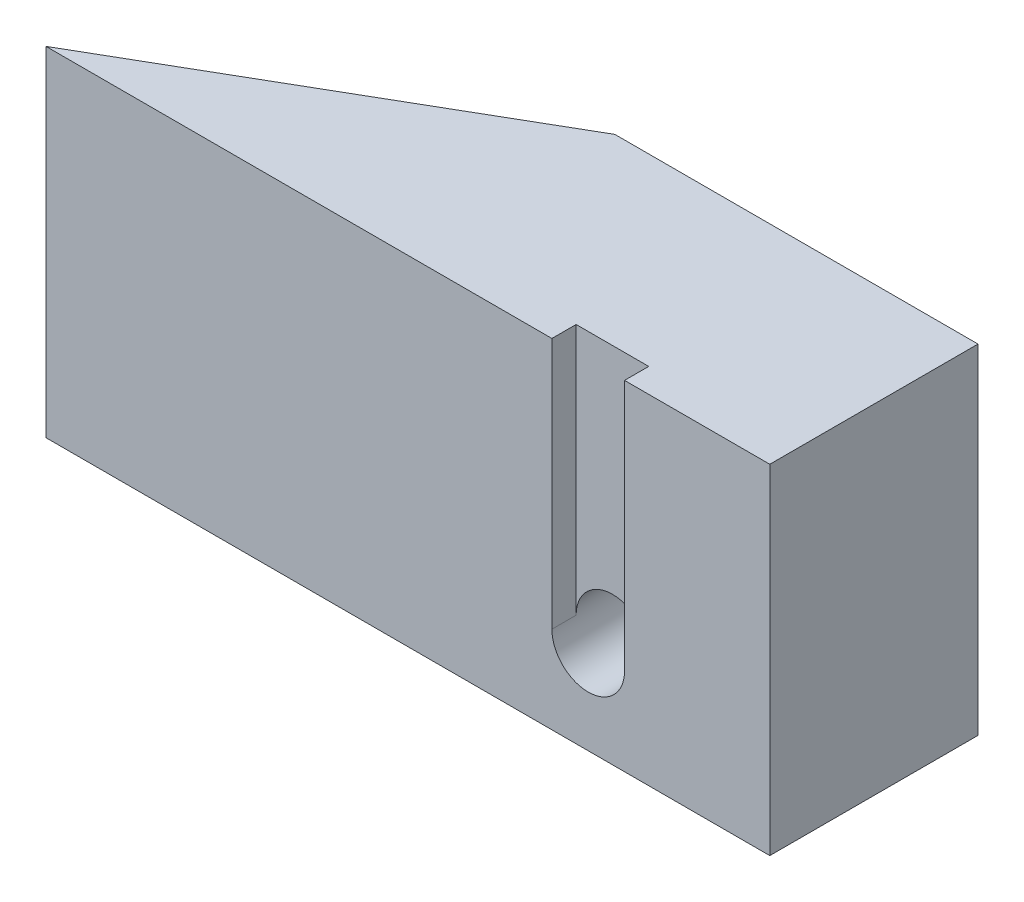
from build123d import *

# Parameters (mm, degrees)
BOSS_EXTRUDE1_DEPTH     = 70
SKETCH3_R               = 3
CUT_EXTRUDE1_DEPTH      = 44
SKETCH7_R               = 7.5
CUT_EXTRUDE3_DEPTH      = 1
CUT_EXTRUDE3_DEPTH_BACK = 30
SKETCH5_W               = 15
SKETCH5_H               = 52
CUT_EXTRUDE2_DEPTH      = 5


with BuildPart() as part:
    # Sketch1 → Boss-Extrude1 (new body)
    with BuildSketch(Plane(origin=(0, 0, 0), x_dir=(1, 0, 0), z_dir=(0, 1, 0))):
        Polygon((-111.978184725, 0), (37.5, 0), (37.5, 43), (-37.5, 43), align=None)
    extrude(amount=BOSS_EXTRUDE1_DEPTH)

    # Sketch3 → Cut-Extrude1 (cut, through all)
    with BuildSketch(Plane.XY):
        with Locations((0, 18)):
            Circle(SKETCH3_R)
    extrude(amount=-CUT_EXTRUDE1_DEPTH, mode=Mode.SUBTRACT)

    # Sketch7 → Cut-Extrude3 (cut, two sides)
    with BuildSketch(Plane.XY) as cut_extrude3_sk:
        with Locations((0, 18)):
            Circle(SKETCH7_R)
    extrude(amount=CUT_EXTRUDE3_DEPTH, mode=Mode.SUBTRACT)
    extrude(cut_extrude3_sk.sketch, amount=-CUT_EXTRUDE3_DEPTH_BACK, mode=Mode.SUBTRACT)

    # Sketch5 → Cut-Extrude2 (cut)
    with BuildSketch(Plane.XY):
        with Locations((0, 44)):
            Rectangle(SKETCH5_W, SKETCH5_H)
    extrude(amount=-CUT_EXTRUDE2_DEPTH, mode=Mode.SUBTRACT)


solid = part.part
